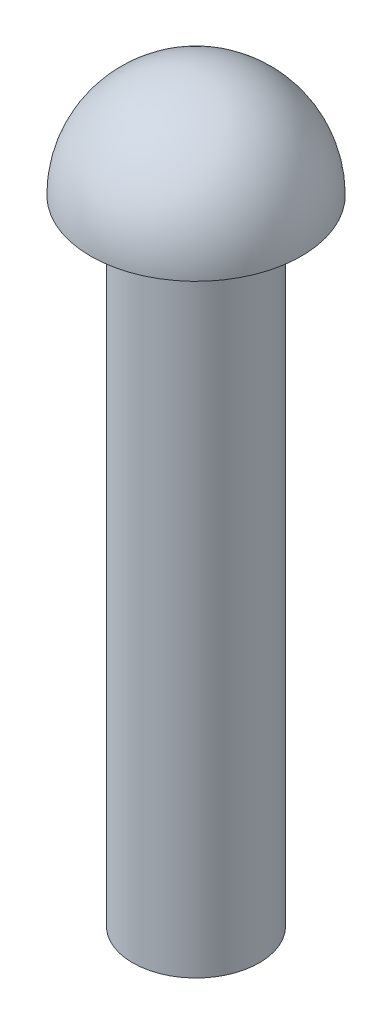
from build123d import *

# Parameters (mm, degrees)
SKETCH1_R           = 3.81
BOSS_EXTRUDE1_DEPTH = 38.1


with BuildPart() as part:
    # Sketch1 → Boss-Extrude1 (new body)
    with BuildSketch(Plane(origin=(0, 0, 0), x_dir=(1, 0, 0), z_dir=(0, 1, 0))):
        Circle(SKETCH1_R)
    extrude(amount=BOSS_EXTRUDE1_DEPTH)

    # Sketch3 → Revolve3 (revolve)
    with BuildSketch(Plane(origin=(0, 0, 0), x_dir=(0, 0, -1), z_dir=(1, 0, 0))):
        with BuildLine():
            Line((0, 38.1), (6.35, 38.1))
            ThreePointArc((6.35, 38.1), (4.490128061, 42.590128061), (0, 44.45))
            Line((0, 44.45), (0, 38.1))
        make_face()
    revolve(axis=Axis((0, 38.1, 0), (0, -1, 0)))


solid = part.part
